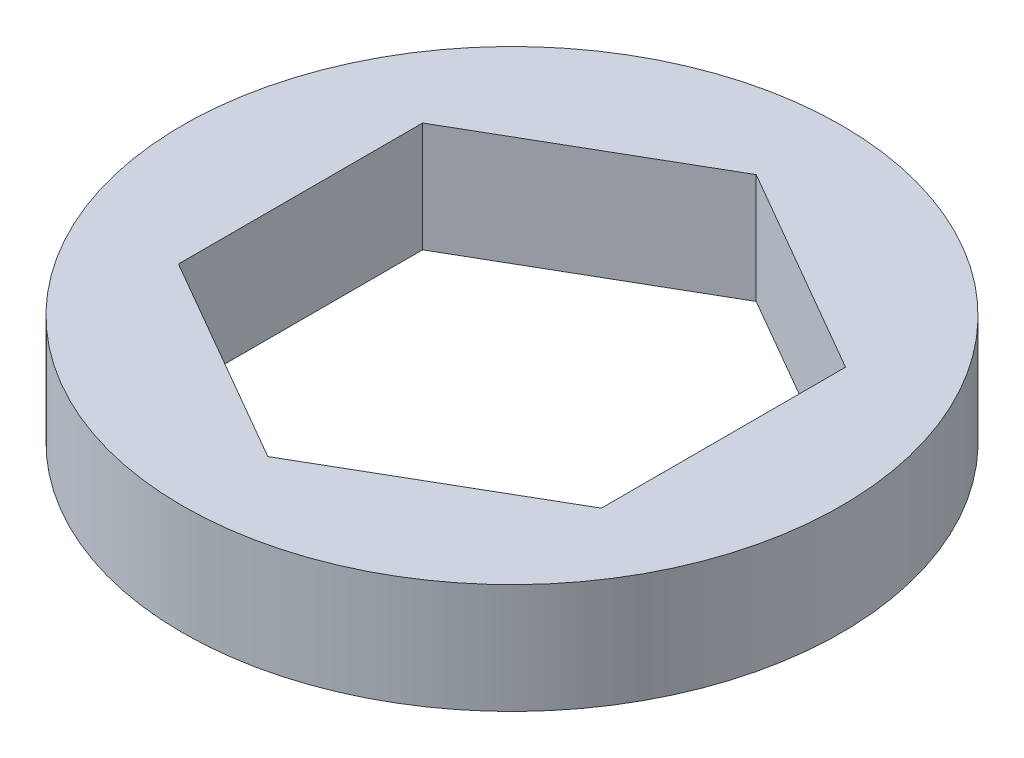
from build123d import *

# Parameters (mm, degrees)
SKETCH1_R           = 7.62
BOSS_EXTRUDE1_DEPTH = 1.27


with BuildPart() as part:
    # Sketch1 → Boss-Extrude1 (new body, symmetric)
    with BuildSketch(Plane(origin=(0, 0, 0), x_dir=(1, 0, 0), z_dir=(0, 1, 0))):
        Circle(SKETCH1_R)
        Polygon((4.8895, -2.822954141), (4.8895, 2.822954141), (0, 5.645908282), (-4.8895, 2.822954141), (-4.8895, -2.822954141), (0, -5.645908282), align=None, mode=Mode.SUBTRACT)
    extrude(amount=BOSS_EXTRUDE1_DEPTH, both=True)


solid = part.part
